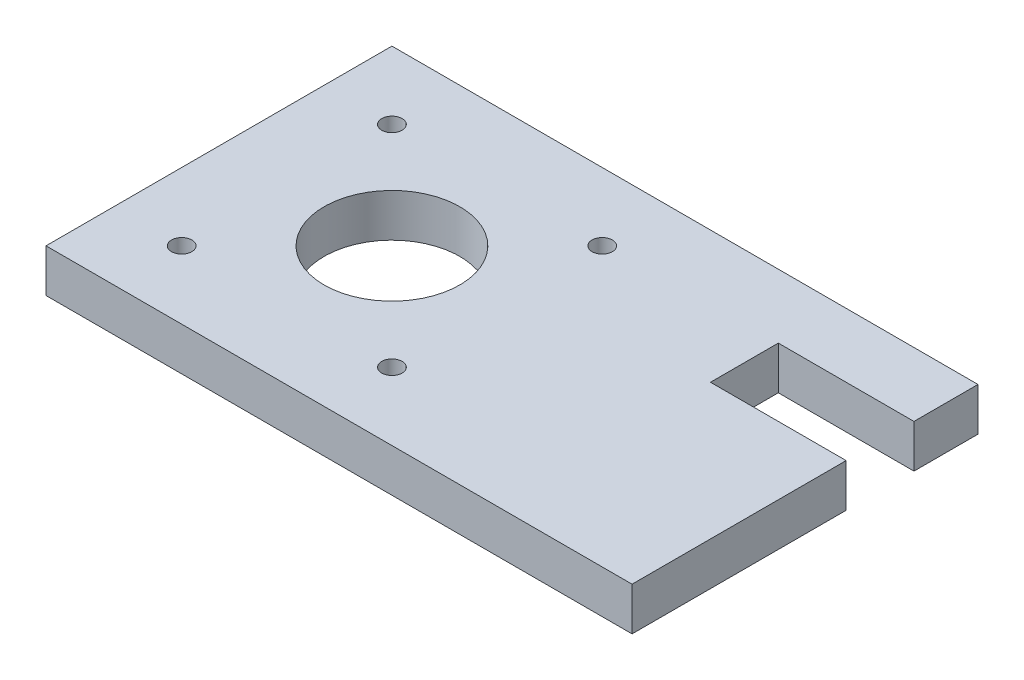
from build123d import *

# Parameters (mm, degrees)
SKETCH1_R           = 1.5
SKETCH1_R_2         = 10
BOSS_EXTRUDE1_DEPTH = 6.35


with BuildPart() as part:
    # Sketch1 → Boss-Extrude1 (new body)
    with BuildSketch(Plane(origin=(0, 0, 0), x_dir=(1, 0, 0), z_dir=(0, 1, 0))):
        Polygon((-25.5, 25.5), (-25.5, -25.5), (50.9, -25.5), (60.9, -25.5), (60.9, 6.061838244), (40.9, 6.061838244), (40.9, 16.061838244), (60.9, 16.061838244), (60.9, 25.5), align=None)
        with Locations((-15.5, 15.5)):
            Circle(SKETCH1_R, mode=Mode.SUBTRACT)
        with Locations((15.5, 15.5)):
            Circle(SKETCH1_R, mode=Mode.SUBTRACT)
        with Locations((15.5, -15.5)):
            Circle(SKETCH1_R, mode=Mode.SUBTRACT)
        with Locations((-15.5, -15.5)):
            Circle(SKETCH1_R, mode=Mode.SUBTRACT)
        Circle(SKETCH1_R_2, mode=Mode.SUBTRACT)
    extrude(amount=BOSS_EXTRUDE1_DEPTH)


solid = part.part
